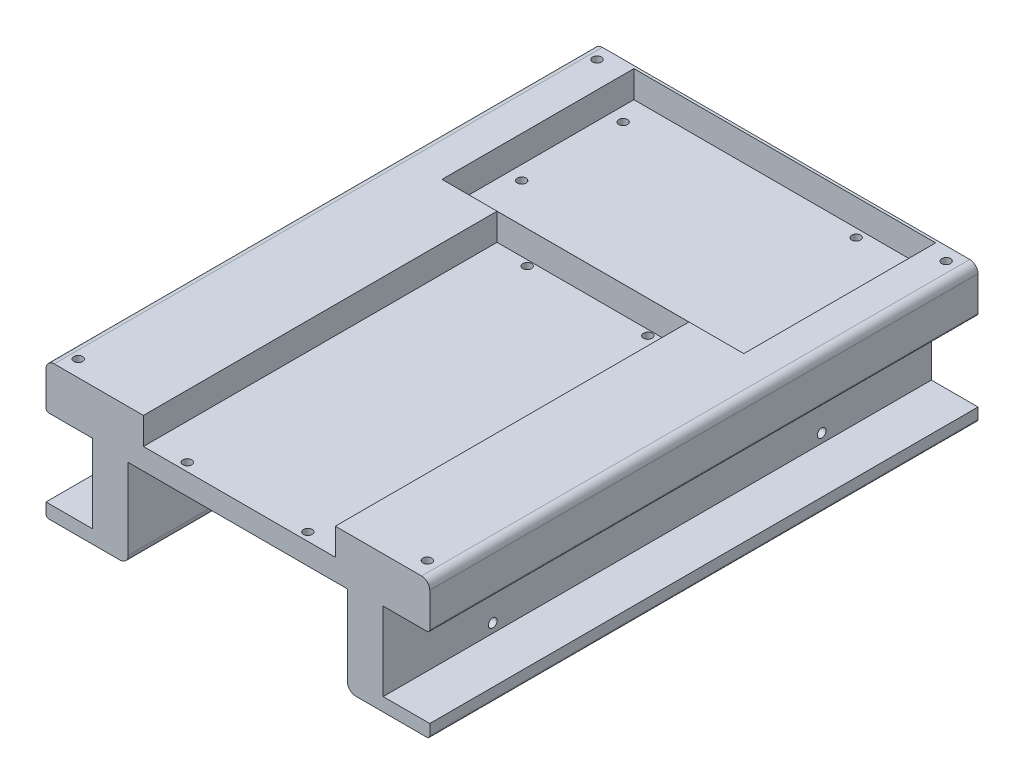
from build123d import *

# Parameters (mm, degrees)
EXTRUDE_2_DEPTH          = 100
SKETCH_4_W               = 110.09382566
SKETCH_4_H               = 70
SKETCH_4_W_2             = 70
SKETCH_4_H_2             = 129.351240965
CUT_EXTRUDE_1_DEPTH      = 10
SKETCH_5_R               = 1.6
CUT_EXTRUDE_2_DEPTH      = 22
SKETCH_6_W               = 17
SKETCH_6_H               = 28.6
CUT_EXTRUDE_3_DEPTH      = 101
CUT_EXTRUDE_3_DEPTH_BACK = 101
SKETCH_7_R               = 1.6
CUT_EXTRUDE_4_DEPTH      = 84.5
FILLET_1_R               = 1
FILLET_2_R               = 3


with BuildPart() as part:
    # 草图1 → 凸台-拉伸2 (new body, symmetric)
    with BuildSketch(Plane.XY):
        Polygon((-40.540540541, -50.17722933), (-40.540540541, -17.800330782), (39.459459459, -17.800330782), (39.459459459, -50.17722933), (69.459459459, -50.17722933), (69.459459459, -0.17722933), (-70.540540541, -0.17722933), (-70.540540541, -50.17722933), align=None)
    extrude(amount=EXTRUDE_2_DEPTH, both=True)

    # 草图4 → 切除-拉伸1 (cut)
    with BuildSketch(Plane(origin=(0, 0, 0), x_dir=(1, 0, 0), z_dir=(0, 1, 0))):
        with Locations((-0.04691283, 64.024061656)):
            Rectangle(SKETCH_4_W, SKETCH_4_H)
        with Locations((0, -35.675620483)):
            Rectangle(SKETCH_4_W_2, SKETCH_4_H_2)
    extrude(amount=-CUT_EXTRUDE_1_DEPTH, mode=Mode.SUBTRACT)

    # 草图5 → 切除-拉伸2 (cut)
    with BuildSketch(Plane(origin=(0, 0, 0), x_dir=(1, 0, 0), z_dir=(0, 1, 0))):
        with Locations((29, 96)):
            Circle(SKETCH_5_R)
        with Locations((-50, 53)):
            Circle(SKETCH_5_R)
        with Locations((28, 35)):
            Circle(SKETCH_5_R)
        with Locations((-50, 90)):
            Circle(SKETCH_5_R)
        with Locations((-22, 27)):
            Circle(SKETCH_5_R)
        with Locations((22, 27)):
            Circle(SKETCH_5_R)
        with Locations((-22, -97)):
            Circle(SKETCH_5_R)
        with Locations((22, -97)):
            Circle(SKETCH_5_R)
        with Locations((-64.69341522, 95.162832005)):
            Circle(SKETCH_5_R)
        with Locations((62.668909511, 95.162832005)):
            Circle(SKETCH_5_R)
        with Locations((62.668909511, -94.06900635)):
            Circle(SKETCH_5_R)
        with Locations((-64.69341522, -94.06900635)):
            Circle(SKETCH_5_R)
    extrude(amount=-CUT_EXTRUDE_2_DEPTH, mode=Mode.SUBTRACT)

    # 草图6 → 切除-拉伸3 (cut, two sides)
    with BuildSketch(Plane.XY) as cut_extrude_3_sk:
        with Locations((-62.040540541, -30.993677516)):
            Rectangle(SKETCH_6_W, SKETCH_6_H)
        with Locations((60.959459459, -30.993677516)):
            Rectangle(SKETCH_6_W, SKETCH_6_H)
    extrude(amount=CUT_EXTRUDE_3_DEPTH, mode=Mode.SUBTRACT)
    extrude(cut_extrude_3_sk.sketch, amount=-CUT_EXTRUDE_3_DEPTH_BACK, mode=Mode.SUBTRACT)

    # 草图7 → 切除-拉伸4 (cut, symmetric)
    with BuildSketch(Plane(origin=(0, 0, 0), x_dir=(0, 0, -1), z_dir=(1, 0, 0))):
        with Locations((-60, -20)):
            Circle(SKETCH_7_R)
        with Locations((-60, -42)):
            Circle(SKETCH_7_R)
        with Locations((60, -42)):
            Circle(SKETCH_7_R)
        with Locations((60, -20)):
            Circle(SKETCH_7_R)
    extrude(amount=CUT_EXTRUDE_4_DEPTH, both=True, mode=Mode.SUBTRACT)

    # 圆角1
    fillet_1_edges = [part.edges().sort_by_distance(p)[0] for p in [
        (-70.540540541, -16.693677516, 0),
        (69.459459459, -16.693677516, 0),
        (69.459459459, -50.17722933, 0),
        (-70.540540541, -50.17722933, 0),
    ]]
    fillet(fillet_1_edges, radius=FILLET_1_R)

    # 圆角2
    fillet_2_edges = [part.edges().sort_by_distance(p)[0] for p in [
        (-70.540540541, -0.17722933, 0),
        (69.459459459, -0.17722933, 0),
        (39.459459459, -50.17722933, 0),
        (-40.540540541, -50.17722933, 0),
    ]]
    fillet(fillet_2_edges, radius=FILLET_2_R)


solid = part.part
